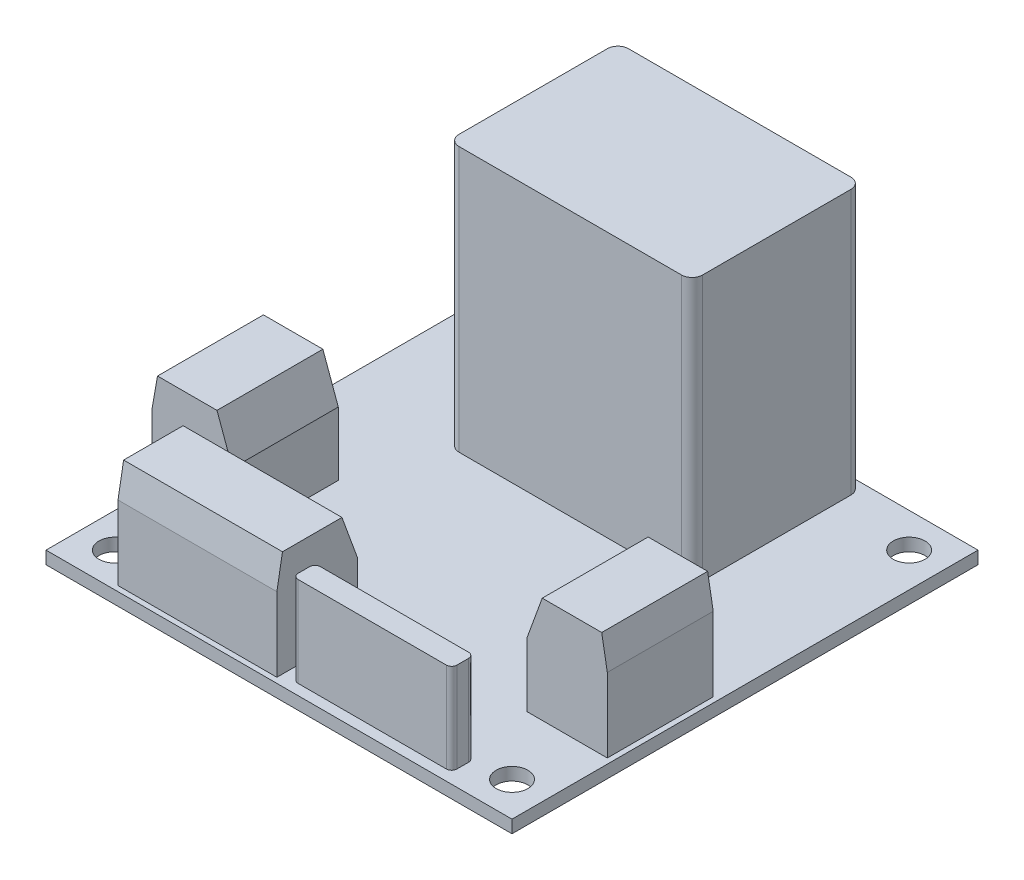
from build123d import *

# Parameters (mm, degrees)
SKETCH1_W             = 44
SKETCH1_H             = 44
BOSS_EXTRUDE1_DEPTH   = 1.2
SKETCH2_W             = 23
SKETCH2_H             = 16
BOSS_EXTRUDE2_DEPTH   = 25
SKETCH3_W             = 7.6
SKETCH3_H             = 10
BOSS_EXTRUDE3_DEPTH   = 10
FILLET1_R             = 1
SKETCH4_W             = 15
SKETCH4_H             = 7.6
BOSS_EXTRUDE4_DEPTH   = 10
CHAMFER2_SIZE         = 3
CHAMFER2_SIZE2        = 0.528980942
CHAMFER2_PART_2_SIZE  = 3
CHAMFER2_PART_2_SIZE2 = 0.528980942
CHAMFER2_PART_3_SIZE  = 3
CHAMFER2_PART_3_SIZE2 = 0.528980942
CHAMFER1_SIZE         = 4
CHAMFER1_SIZE2        = 1.455880937
CHAMFER1_PART_2_SIZE  = 4
CHAMFER1_PART_2_SIZE2 = 1.455880937
CHAMFER1_PART_3_SIZE  = 4
CHAMFER1_PART_3_SIZE2 = 1.455880937
SKETCH5_W             = 15
SKETCH5_H             = 2.1
BOSS_EXTRUDE5_DEPTH   = 8.5
FILLET2_R             = 0.5
SKETCH6_R             = 1.5
CUT_EXTRUDE1_DEPTH    = 2.2


with BuildPart() as part:
    # Sketch1 → Boss-Extrude1 (new body)
    with BuildSketch(Plane(origin=(0, 0, 0), x_dir=(1, 0, 0), z_dir=(0, 1, 0))):
        Rectangle(SKETCH1_W, SKETCH1_H)
    extrude(amount=BOSS_EXTRUDE1_DEPTH)

    # Sketch2 → Boss-Extrude2 (add)
    with BuildSketch(Plane(origin=(0, 1.2, 0), x_dir=(1, 0, 0), z_dir=(0, 1, 0))):
        with Locations((0, 13.5)):
            Rectangle(SKETCH2_W, SKETCH2_H)
    extrude(amount=BOSS_EXTRUDE2_DEPTH)

    # Sketch3 → Boss-Extrude3 (add)
    with BuildSketch(Plane(origin=(0, 1.2, 0), x_dir=(1, 0, 0), z_dir=(0, 1, 0))):
        with Locations((-17.7, -7.5)):
            Rectangle(SKETCH3_W, SKETCH3_H)
    boss_extrude3 = extrude(amount=BOSS_EXTRUDE3_DEPTH)

    # Mirror1: Boss-Extrude3 across plane
    add(boss_extrude3.mirror(Plane(origin=(0, 0, 0), x_dir=(0, 0, 1), z_dir=(1, 0, 0))))

    # Fillet1
    fillet1_edges = [part.edges().sort_by_distance(p)[0] for p in [
        (-11.5, 13.7, -21.5),
        (-11.5, 13.7, -5.5),
        (11.5, 13.7, -5.5),
        (11.5, 13.7, -21.5),
    ]]
    fillet(fillet1_edges, radius=FILLET1_R)

    # Sketch4 → Boss-Extrude4 (add)
    with BuildSketch(Plane(origin=(0, 1.2, 0), x_dir=(1, 0, 0), z_dir=(0, 1, 0))):
        with Locations((-8.2, -17.7)):
            Rectangle(SKETCH4_W, SKETCH4_H)
    extrude(amount=BOSS_EXTRUDE4_DEPTH)

    # Chamfer2
    chamfer2_edges = [part.edges().sort_by_distance(p)[0] for p in [
        (-21.5, 11.2, 7.5),
    ]]
    chamfer2_side = [part.faces().sort_by_distance(p)[0] for p in [
        (-21.5, 6.2, 7.5),
    ]]
    chamfer(chamfer2_edges, length=CHAMFER2_SIZE, length2=CHAMFER2_SIZE2, reference=chamfer2_side[0])

    # Chamfer2 part 2
    chamfer2_part_2_edges = [part.edges().sort_by_distance(p)[0] for p in [
        (21.5, 11.2, 7.5),
    ]]
    chamfer2_part_2_side = [part.faces().sort_by_distance(p)[0] for p in [
        (21.5, 6.2, 7.5),
    ]]
    chamfer(chamfer2_part_2_edges, length=CHAMFER2_PART_2_SIZE, length2=CHAMFER2_PART_2_SIZE2, reference=chamfer2_part_2_side[0])

    # Chamfer2 part 3
    chamfer2_part_3_edges = [part.edges().sort_by_distance(p)[0] for p in [
        (-8.2, 11.2, 21.5),
    ]]
    chamfer2_part_3_side = [part.faces().sort_by_distance(p)[0] for p in [
        (-8.2, 6.2, 21.5),
    ]]
    chamfer(chamfer2_part_3_edges, length=CHAMFER2_PART_3_SIZE, length2=CHAMFER2_PART_3_SIZE2, reference=chamfer2_part_3_side[0])

    # Chamfer1
    chamfer1_edges = [part.edges().sort_by_distance(p)[0] for p in [
        (-13.9, 11.2, 7.5),
    ]]
    chamfer1_side = [part.faces().sort_by_distance(p)[0] for p in [
        (-13.9, 6.2, 7.5),
    ]]
    chamfer(chamfer1_edges, length=CHAMFER1_SIZE, length2=CHAMFER1_SIZE2, reference=chamfer1_side[0])

    # Chamfer1 part 2
    chamfer1_part_2_edges = [part.edges().sort_by_distance(p)[0] for p in [
        (13.9, 11.2, 7.5),
    ]]
    chamfer1_part_2_side = [part.faces().sort_by_distance(p)[0] for p in [
        (13.9, 6.2, 7.5),
    ]]
    chamfer(chamfer1_part_2_edges, length=CHAMFER1_PART_2_SIZE, length2=CHAMFER1_PART_2_SIZE2, reference=chamfer1_part_2_side[0])

    # Chamfer1 part 3
    chamfer1_part_3_edges = [part.edges().sort_by_distance(p)[0] for p in [
        (-8.2, 11.2, 13.9),
    ]]
    chamfer1_part_3_side = [part.faces().sort_by_distance(p)[0] for p in [
        (-8.2, 6.2, 13.9),
    ]]
    chamfer(chamfer1_part_3_edges, length=CHAMFER1_PART_3_SIZE, length2=CHAMFER1_PART_3_SIZE2, reference=chamfer1_part_3_side[0])

    # Sketch5 → Boss-Extrude5 (add)
    with BuildSketch(Plane(origin=(0, 1.2, 0), x_dir=(1, 0, 0), z_dir=(0, 1, 0))):
        with Locations((7.8, -19.95)):
            Rectangle(SKETCH5_W, SKETCH5_H)
    extrude(amount=BOSS_EXTRUDE5_DEPTH)

    # Fillet2
    fillet2_edges = [part.edges().sort_by_distance(p)[0] for p in [
        (0.3, 5.45, 18.9),
        (0.3, 5.45, 21),
        (15.3, 5.45, 21),
        (15.3, 5.45, 18.9),
    ]]
    fillet(fillet2_edges, radius=FILLET2_R)

    # Sketch6 → Cut-Extrude1 (cut, through all)
    with BuildSketch(Plane(origin=(0, 1.2, 0), x_dir=(1, 0, 0), z_dir=(0, 1, 0))):
        with Locations((-18.75, 18.75)):
            Circle(SKETCH6_R)
        with Locations((18.75, 18.75)):
            Circle(SKETCH6_R)
        with Locations((18.75, -18.75)):
            Circle(SKETCH6_R)
        with Locations((-18.75, -18.75)):
            Circle(SKETCH6_R)
    extrude(amount=-CUT_EXTRUDE1_DEPTH, mode=Mode.SUBTRACT)


solid = part.part
